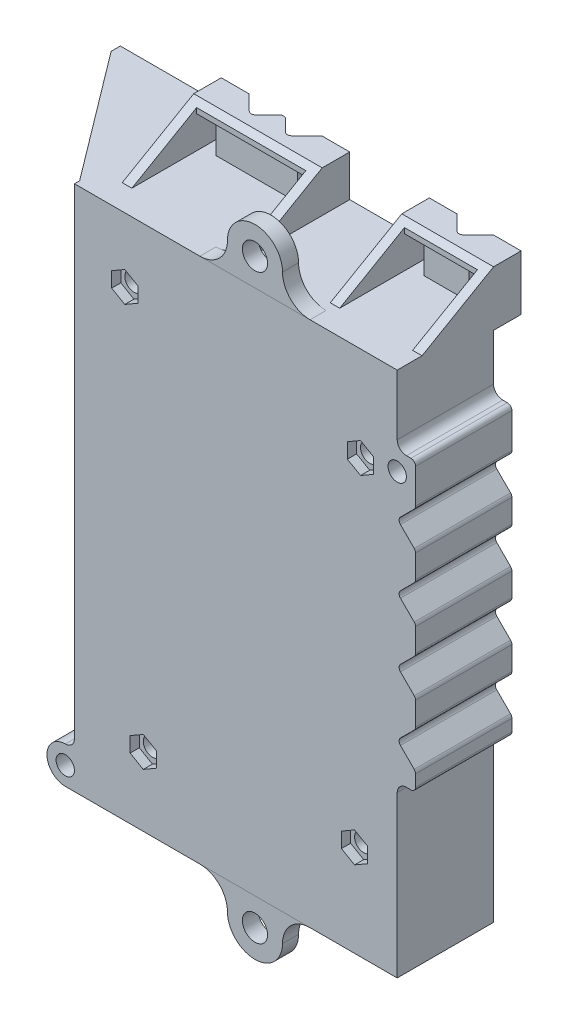
from build123d import *

# Parameters (mm, degrees)
BOSS_EXTRUDE1_DEPTH   = 21
FILLET1_R             = 2
SKETCH2_W             = 64.35
SKETCH2_H             = 108.75
CUT_EXTRUDE1_DEPTH    = 17.5
SKETCH3_R             = 2.75
BOSS_EXTRUDE2_DEPTH   = 3.5
BOSS_EXTRUDE2_2_DEPTH = 3.5
BOSS_EXTRUDE4_DEPTH   = 21
SKETCH6_R             = 2
CUT_EXTRUDE2_DEPTH    = 22
BOSS_EXTRUDE5_DEPTH   = 10
SKETCH8_R             = 2
CUT_EXTRUDE3_DEPTH    = 10
BOSS_EXTRUDE6_DEPTH   = 23
CUT_EXTRUDE5_DEPTH    = 17
SKETCH11_W            = 1.027963803
SKETCH11_H            = 17
CUT_EXTRUDE6_DEPTH    = 27.5
SKETCH12_W            = 67.35
SKETCH12_H            = 3
CUT_EXTRUDE7_DEPTH    = 4
SKETCH13_W            = 15
SKETCH13_H            = 13
CUT_EXTRUDE8_DEPTH    = 4
BOSS_EXTRUDE7_DEPTH   = 20
CUT_EXTRUDE9_DEPTH    = 20
CUT_EXTRUDE10_START   = -21.58846
SKETCH16_W            = 3.00025
SKETCH16_H            = 7.000001577
CUT_EXTRUDE10_DEPTH   = 21.58846
SKETCH17_W            = 15.9
SKETCH17_H            = 8.154711577
CUT_EXTRUDE11_DEPTH   = 19.5359
SKETCH18_W            = 9.8995
SKETCH18_H            = 7.000001577
CUT_EXTRUDE12_DEPTH   = 1.2
BOSS_EXTRUDE8_DEPTH   = 9
CUT_EXTRUDE13_DEPTH   = 9
BOSS_EXTRUDE9_DEPTH   = 28
CUT_EXTRUDE14_START   = -21.58846
SKETCH21_W            = 3
SKETCH21_H            = 7
CUT_EXTRUDE14_DEPTH   = 21.58846
SKETCH24_W            = 23.8
SKETCH24_H            = 8.15471
CUT_EXTRUDE15_DEPTH   = 16.0359
SKETCH25_W            = 17.8
SKETCH25_H            = 7
CUT_EXTRUDE16_DEPTH   = 1.2
BOSS_EXTRUDE10_DEPTH  = 3.5
SKETCH27_R            = 2
CUT_EXTRUDE20_DEPTH   = 4.5
CUT_EXTRUDE21_DEPTH   = 2
SKETCH34_R            = 4
SKETCH34_R_2          = 2
BOSS_EXTRUDE12_DEPTH  = 2
FILLET3_R             = 4
SKETCH35_R            = 2
CUT_EXTRUDE22_DEPTH   = 22
BOSS_EXTRUDE13_DEPTH  = 4
CUT_EXTRUDE23_START   = -7
SKETCH38_R            = 2
CUT_EXTRUDE23_DEPTH   = 4
CUT_EXTRUDE24_DEPTH   = 3


with BuildPart() as part:
    # Sketch1 → Boss-Extrude1 (new body)
    with BuildSketch(Plane.XY):
        with BuildLine():
            Line((38.175, 42.225), (35.175, 42.225))
            Line((35.175, 42.225), (35.175, 57.375))
            Line((35.175, 57.375), (-35.175, 57.375))
            Line((-35.175, 57.375), (-35.175, -57.375))
            Line((-35.175, -57.375), (35.175, -57.375))
            Line((35.175, -57.375), (35.175, -20.375))
            Line((35.175, -20.375), (38.175, -20.375))
            ThreePointArc((38.175, -20.375), (38.882106781, -20.082106781), (39.175, -19.375))
            Line((39.175, -19.375), (39.175, -16.839213562))
            ThreePointArc((39.175, -16.839213562), (39.098879533, -16.45653013), (38.882106781, -16.132106781))
            Line((38.882106781, -16.132106781), (35.882106781, -13.132106781))
            ThreePointArc((35.882106781, -13.132106781), (35.589213562, -12.425), (35.882106781, -11.717893219))
            Line((35.882106781, -11.717893219), (38.882106781, -8.717893219))
            ThreePointArc((38.882106781, -8.717893219), (39.098879533, -8.39346987), (39.175, -8.010786438))
            Line((39.175, -8.010786438), (39.175, -2.939213562))
            ThreePointArc((39.175, -2.939213562), (39.098879533, -2.55653013), (38.882106781, -2.232106781))
            Line((38.882106781, -2.232106781), (35.882106781, 0.767893219))
            ThreePointArc((35.882106781, 0.767893219), (35.589213562, 1.475), (35.882106781, 2.182106781))
            Line((35.882106781, 2.182106781), (38.882106781, 5.182106781))
            ThreePointArc((38.882106781, 5.182106781), (39.098879533, 5.50653013), (39.175, 5.889213562))
            Line((39.175, 5.889213562), (39.175, 10.960786438))
            ThreePointArc((39.175, 10.960786438), (39.098879533, 11.34346987), (38.882106781, 11.667893219))
            Line((38.882106781, 11.667893219), (35.882106781, 14.667893219))
            ThreePointArc((35.882106781, 14.667893219), (35.589213562, 15.375), (35.882106781, 16.082106781))
            Line((35.882106781, 16.082106781), (38.882106781, 19.082106781))
            ThreePointArc((38.882106781, 19.082106781), (39.098879533, 19.40653013), (39.175, 19.789213562))
            Line((39.175, 19.789213562), (39.175, 24.860786438))
            ThreePointArc((39.175, 24.860786438), (39.098879533, 25.24346987), (38.882106781, 25.567893219))
            Line((38.882106781, 25.567893219), (35.882106781, 28.567893219))
            ThreePointArc((35.882106781, 28.567893219), (35.589213562, 29.275), (35.882106781, 29.982106781))
            Line((35.882106781, 29.982106781), (38.882106781, 32.982106781))
            ThreePointArc((38.882106781, 32.982106781), (39.098879533, 33.30653013), (39.175, 33.689213562))
            Line((39.175, 33.689213562), (39.175, 41.225))
            ThreePointArc((39.175, 41.225), (38.882106781, 41.932106781), (38.175, 42.225))
        make_face()
    extrude(amount=BOSS_EXTRUDE1_DEPTH)

    # Fillet1
    fillet1_edges = [part.edges().sort_by_distance(p)[0] for p in [
        (35.175, 42.225, 10.5),
        (35.175, -20.375, 10.5),
    ]]
    fillet(fillet1_edges, radius=FILLET1_R)

    # Sketch2 → Cut-Extrude1 (cut)
    with BuildSketch(Plane(origin=(0, 0, 0), x_dir=(-1, 0, 0), z_dir=(0, 0, -1))):
        Rectangle(SKETCH2_W, SKETCH2_H)
    extrude(amount=-CUT_EXTRUDE1_DEPTH, mode=Mode.SUBTRACT)

    # Sketch5 → Boss-Extrude4 (add)
    with BuildSketch(Plane.XY.offset(21)):
        with BuildLine():
            Line((-35.175, -47.375), (-35.175, -57.375))
            Line((-35.175, -57.375), (-37.175, -57.375))
            ThreePointArc((-37.175, -57.375), (-41.175, -53.375), (-37.175, -49.375))
            ThreePointArc((-37.175, -49.375), (-35.760786438, -48.789213562), (-35.175, -47.375))
        make_face()
    extrude(amount=-BOSS_EXTRUDE4_DEPTH)

    # Sketch6 → Cut-Extrude2 (cut, through all)
    with BuildSketch(Plane.XY.offset(21)):
        with Locations((-37.175, -53.375)):
            Circle(SKETCH6_R)
    extrude(amount=-CUT_EXTRUDE2_DEPTH, mode=Mode.SUBTRACT)

    # Sketch7 → Boss-Extrude5 (add)
    with BuildSketch(Plane(origin=(0, 0, 0), x_dir=(-1, 0, 0), z_dir=(0, 0, -1))):
        Polygon((-35.175, 57.375), (-35.175, 54.375), (32.175, 54.375), (32.175, 22.375), (35.175, 22.375), (35.175, 57.375), align=None)
    extrude(amount=BOSS_EXTRUDE5_DEPTH)

    # Sketch8 → Cut-Extrude3 (cut)
    with BuildSketch(Plane.ZY.offset(35.175)):
        with Locations((8.68916164, -13.263185313)):
            Circle(SKETCH8_R)
        with Locations((8.68916164, 22.513185313)):
            Circle(SKETCH8_R)
        with BuildLine():
            Line((0, -13.841185313), (0, 22.375))
            Line((0, 22.375), (-10, 22.375))
            Line((-10, 22.375), (-10, 25.625))
            ThreePointArc((-10, 25.625), (10.356692899, 9.783008745), (0, -13.841185313))
        make_face()
    extrude(amount=-CUT_EXTRUDE3_DEPTH, mode=Mode.SUBTRACT)

    # Sketch9 → Boss-Extrude6 (add)
    with BuildSketch(Plane(origin=(0, 57.375, 0), x_dir=(1, 0, 0), z_dir=(0, 1, 0))):
        Polygon((-35.175, -19.86794), (-56.174999055, 8), (-56.174999055, 10), (-35.175, 10), align=None)
    extrude(amount=-BOSS_EXTRUDE6_DEPTH)

    # Sketch10 → Cut-Extrude5 (cut)
    with BuildSketch(Plane(origin=(0, 54.375, 0), x_dir=(1, 0, 0), z_dir=(0, 1, 0))):
        Polygon((-33.202963803, 10), (-33.202963803, -17.5), (-53.925700181, 10), align=None)
    extrude(amount=-CUT_EXTRUDE5_DEPTH, mode=Mode.SUBTRACT)

    # Sketch11 → Cut-Extrude6 (cut)
    with BuildSketch(Plane(origin=(0, 0, -10), x_dir=(-1, 0, 0), z_dir=(0, 0, -1))):
        with Locations((32.688981902, 45.875)):
            Rectangle(SKETCH11_W, SKETCH11_H)
    extrude(amount=-CUT_EXTRUDE6_DEPTH, mode=Mode.SUBTRACT)

    # Sketch12 → Cut-Extrude7 (cut)
    with BuildSketch(Plane(origin=(0, 0, -10), x_dir=(-1, 0, 0), z_dir=(0, 0, -1))):
        with Locations((-1.5, 55.875)):
            Rectangle(SKETCH12_W, SKETCH12_H)
    extrude(amount=-CUT_EXTRUDE7_DEPTH, mode=Mode.SUBTRACT)

    # Sketch13 → Cut-Extrude8 (cut)
    with BuildSketch(Plane.XZ.offset(57.375)):
        with Locations((14.975, 6.5)):
            Rectangle(SKETCH13_W, SKETCH13_H)
    extrude(amount=-CUT_EXTRUDE8_DEPTH, mode=Mode.SUBTRACT)

    # Sketch14 → Boss-Extrude7 (add)
    with BuildSketch(Plane(origin=(35.175, 0, 0), x_dir=(0, 0, -1), z_dir=(1, 0, 0))):
        Polygon((-15.58846, 57.375), (0, 66.375001577), (6, 66.375001577), (6, 57.375), align=None)
    extrude(amount=-BOSS_EXTRUDE7_DEPTH)

    # Sketch15 → Cut-Extrude9 (cut)
    with BuildSketch(Plane(origin=(0, 66.375001577, 0), x_dir=(1, 0, 0), z_dir=(0, 1, 0))):
        with BuildLine():
            Line((25.882106079, 2.757362517), (29.12475, 6))
            Line((29.12475, 6), (21.22525, 6))
            Line((21.22525, 6), (24.467893921, 2.757362517))
            ThreePointArc((24.467893921, 2.757362517), (25.175, 2.46447), (25.882106079, 2.757362517))
        make_face()
    extrude(amount=-CUT_EXTRUDE9_DEPTH, mode=Mode.SUBTRACT)

    # Sketch16 → Cut-Extrude10 (cut)
    with BuildSketch(Plane(origin=(0, 0, -6), x_dir=(-1, 0, 0), z_dir=(0, 0, -1)).offset(CUT_EXTRUDE10_START)):
        with Locations((-18.725125, 60.875000789)):
            Rectangle(SKETCH16_W, SKETCH16_H)
        with Locations((-31.624875, 60.875000789)):
            Rectangle(SKETCH16_W, SKETCH16_H)
    extrude(amount=CUT_EXTRUDE10_DEPTH, mode=Mode.SUBTRACT)

    # Sketch17 → Cut-Extrude11 (cut)
    with BuildSketch(Plane.XY.offset(21)):
        with Locations((25.175, 61.452355789)):
            Rectangle(SKETCH17_W, SKETCH17_H)
    extrude(amount=-CUT_EXTRUDE11_DEPTH, mode=Mode.SUBTRACT)

    # Sketch18 → Cut-Extrude12 (cut)
    with BuildSketch(Plane.XY.offset(1.4641)):
        with Locations((25.175, 60.875000789)):
            Rectangle(SKETCH18_W, SKETCH18_H)
    extrude(amount=-CUT_EXTRUDE12_DEPTH, mode=Mode.SUBTRACT)

    # Sketch19 → Boss-Extrude8 (add)
    with BuildSketch(Plane(origin=(0, 57.375, 0), x_dir=(1, 0, 0), z_dir=(0, 1, 0))):
        with BuildLine():
            Line((-30.175, 6), (-24.075, 6))
            Line((-24.075, 6), (-20.832106781, 2.757106781))
            ThreePointArc((-20.832106781, 2.757106781), (-20.125, 2.464213562), (-19.417893219, 2.757106781))
            Line((-19.417893219, 2.757106781), (-16.882106781, 5.292893219))
            ThreePointArc((-16.882106781, 5.292893219), (-16.175, 5.585786438), (-15.467893219, 5.292893219))
            Line((-15.467893219, 5.292893219), (-12.932106781, 2.757106781))
            ThreePointArc((-12.932106781, 2.757106781), (-12.225, 2.464213562), (-11.517893219, 2.757106781))
            Line((-11.517893219, 2.757106781), (-8.275, 6))
            Line((-8.275, 6), (-2.175, 6))
            Line((-2.175, 6), (-2.175, 0))
            Line((-2.175, 0), (-30.175, 0))
            Line((-30.175, 0), (-30.175, 6))
        make_face()
    extrude(amount=BOSS_EXTRUDE8_DEPTH)

    # Sketch20 → Cut-Extrude13 (cut)
    with BuildSketch(Plane(origin=(0, 57.375, 0), x_dir=(1, 0, 0), z_dir=(0, 1, 0))):
        with BuildLine():
            Line((-24.075, 6), (-8.275, 6))
            Line((-8.275, 6), (-11.517893219, 2.757106781))
            ThreePointArc((-11.517893219, 2.757106781), (-12.225, 2.464213562), (-12.932106781, 2.757106781))
            Line((-12.932106781, 2.757106781), (-15.467893219, 5.292893219))
            ThreePointArc((-15.467893219, 5.292893219), (-16.175, 5.585786438), (-16.882106781, 5.292893219))
            Line((-16.882106781, 5.292893219), (-19.417893219, 2.757106781))
            ThreePointArc((-19.417893219, 2.757106781), (-20.125, 2.464213562), (-20.832106781, 2.757106781))
            Line((-20.832106781, 2.757106781), (-24.075, 6))
        make_face()
    extrude(amount=-CUT_EXTRUDE13_DEPTH, mode=Mode.SUBTRACT)

    # Sketch23 → Boss-Extrude9 (add)
    with BuildSketch(Plane.ZY.offset(30.175)):
        Polygon((0, 66.375), (15.58846, 57.375), (0, 57.375), align=None)
    extrude(amount=-BOSS_EXTRUDE9_DEPTH)

    # Sketch21 → Cut-Extrude14 (cut)
    with BuildSketch(Plane(origin=(0, 0, -6), x_dir=(-1, 0, 0), z_dir=(0, 0, -1)).offset(CUT_EXTRUDE14_START)):
        with Locations((26.575, 60.875)):
            Rectangle(SKETCH21_W, SKETCH21_H)
        with Locations((5.775, 60.875)):
            Rectangle(SKETCH21_W, SKETCH21_H)
    extrude(amount=CUT_EXTRUDE14_DEPTH, mode=Mode.SUBTRACT)

    # Sketch24 → Cut-Extrude15 (cut)
    with BuildSketch(Plane.XY.offset(17.5)):
        with Locations((-16.175, 61.452355)):
            Rectangle(SKETCH24_W, SKETCH24_H)
    extrude(amount=-CUT_EXTRUDE15_DEPTH, mode=Mode.SUBTRACT)

    # Sketch25 → Cut-Extrude16 (cut)
    with BuildSketch(Plane.XY.offset(1.4641)):
        with Locations((-16.175, 60.875)):
            Rectangle(SKETCH25_W, SKETCH25_H)
    extrude(amount=-CUT_EXTRUDE16_DEPTH, mode=Mode.SUBTRACT)

    # Sketch26 → Boss-Extrude10 (add)
    with BuildSketch(Plane(origin=(0, 0, 17.5), x_dir=(-1, 0, 0), z_dir=(0, 0, -1))):
        with BuildLine():
            Line((-19.175, 31.875), (-19.175, -26.875))
            ThreePointArc((-19.175, -26.875), (-21.675, -29.375), (-24.175, -26.875))
            Line((-24.175, -26.875), (-24.175, 31.875))
            ThreePointArc((-24.175, 31.875), (-21.675, 34.375), (-19.175, 31.875))
        make_face()
        with BuildLine():
            Line((17.04135, 31.875), (17.04135, -26.875))
            ThreePointArc((17.04135, -26.875), (14.54135, -29.375), (12.04135, -26.875))
            Line((12.04135, -26.875), (12.04135, 31.875))
            ThreePointArc((12.04135, 31.875), (14.54135, 34.375), (17.04135, 31.875))
        make_face()
    extrude(amount=BOSS_EXTRUDE10_DEPTH)

    # Sketch27 → Cut-Extrude20 (cut, through all)
    with BuildSketch(Plane(origin=(0, 0, 17.5), x_dir=(-1, 0, 0), z_dir=(0, 0, -1))):
        with Locations((20.175, -42.375)):
            Circle(SKETCH27_R)
        with Locations((-25.875, -37.375)):
            Circle(SKETCH27_R)
        with Locations((24.202963803, 43.375)):
            Circle(SKETCH27_R)
        with Locations((-27.175, 36.775)):
            Circle(SKETCH27_R)
    extrude(amount=-CUT_EXTRUDE20_DEPTH, mode=Mode.SUBTRACT)

    # Sketch32 → Cut-Extrude21 (cut)
    with BuildSketch(Plane.XY.offset(21)):
        Polygon((-21.34507997, 41.725), (-21.34507997, 45.025), (-24.202963803, 46.675), (-27.060847635, 45.025), (-27.060847635, 41.725), (-24.202963803, 40.075), align=None)
        Polygon((30.032883832, 35.125), (30.032883832, 38.425), (27.175, 40.075), (24.317116168, 38.425), (24.317116168, 35.125), (27.175, 33.475), align=None)
        Polygon((-17.317116168, -44.025), (-17.317116168, -40.725), (-20.175, -39.075), (-23.032883832, -40.725), (-23.032883832, -44.025), (-20.175, -45.675), align=None)
        Polygon((28.732883832, -39.025), (28.732883832, -35.725), (25.875, -34.075), (23.017116168, -35.725), (23.017116168, -39.025), (25.875, -40.675), align=None)
    extrude(amount=-CUT_EXTRUDE21_DEPTH, mode=Mode.SUBTRACT)

    # Sketch34 → Boss-Extrude12 (add)
    with BuildSketch(Plane(origin=(0, 0, 17.5), x_dir=(-1, 0, 0), z_dir=(0, 0, -1))):
        with Locations((-27.175, 36.775)):
            Circle(SKETCH34_R)
        with Locations((-27.175, 36.775)):
            Circle(SKETCH34_R_2, mode=Mode.SUBTRACT)
        with BuildLine():
            ThreePointArc((-27.175, 32.775), (-31.175, 36.775), (-27.175, 40.775))
            Line((-27.175, 40.775), (-32.175, 40.775))
            Line((-32.175, 40.775), (-32.175, 32.775))
            Line((-32.175, 32.775), (-27.175, 32.775))
        make_face()
        with Locations((24.112183156, 43.39205956)):
            Circle(SKETCH34_R)
        with Locations((24.202963803, 43.375)):
            Circle(SKETCH34_R_2, mode=Mode.SUBTRACT)
        with Locations((20.175, -42.375)):
            Circle(SKETCH34_R)
        with Locations((20.175, -42.375)):
            Circle(SKETCH34_R_2, mode=Mode.SUBTRACT)
        with BuildLine():
            Line((-25.875, -33.375), (-32.175, -33.375))
            Line((-32.175, -33.375), (-32.175, -41.375))
            Line((-32.175, -41.375), (-25.875, -41.375))
            ThreePointArc((-25.875, -41.375), (-29.875, -37.375), (-25.875, -33.375))
        make_face()
        with Locations((-25.875, -37.375)):
            Circle(SKETCH34_R)
        with Locations((-25.875, -37.375)):
            Circle(SKETCH34_R_2, mode=Mode.SUBTRACT)
    extrude(amount=BOSS_EXTRUDE12_DEPTH)

    # Fillet3
    fillet3_edges = [part.edges().sort_by_distance(p)[0] for p in [
        (32.175, 40.775, 16.5),
        (32.175, 32.775, 16.5),
        (32.175, -41.375, 16.5),
        (32.175, -33.375, 16.5),
    ]]
    fillet(fillet3_edges, radius=FILLET3_R)

    # Sketch35 → Cut-Extrude22 (cut, through all)
    with BuildSketch(Plane(origin=(0, 0, 0), x_dir=(-1, 0, 0), z_dir=(0, 0, -1))):
        with Locations((-35.175, 38.225)):
            Circle(SKETCH35_R)
    extrude(amount=-CUT_EXTRUDE22_DEPTH, mode=Mode.SUBTRACT)

    # Sketch36 → Boss-Extrude13 (add)
    with BuildSketch(Plane(origin=(-32.175, 0, 0), x_dir=(0, 0, -1), z_dir=(1, 0, 0))):
        with BuildLine():
            Line((-17.5, 27.496380363), (-17.5, 15.496380363))
            Line((-17.5, 15.496380363), (-7.967, 15.496380363))
            ThreePointArc((-7.967, 15.496380363), (-6.376511507, 17.770716825), (-4.5, 19.815457531))
            Line((-4.5, 19.815457531), (-4.5, 27.496380363))
            Line((-4.5, 27.496380363), (-17.5, 27.496380363))
        make_face()
    boss_extrude13 = extrude(amount=BOSS_EXTRUDE13_DEPTH)

    # Mirror1: Boss-Extrude13 across plane
    add(boss_extrude13.mirror(Plane(origin=(0, 4.625, 0), x_dir=(0, 0, 1), z_dir=(0, -1, 0))))

    # Sketch38 → Cut-Extrude23 (cut)
    with BuildSketch(Plane.ZY.offset(35.175).offset(CUT_EXTRUDE23_START)):
        with Locations((8.68916164, -13.263185313)):
            Circle(SKETCH38_R)
        with Locations((8.68916164, 22.513185313)):
            Circle(SKETCH38_R)
    extrude(amount=CUT_EXTRUDE23_DEPTH, mode=Mode.SUBTRACT)

    # Sketch39 → Cut-Extrude24 (cut)
    with BuildSketch(Plane(origin=(-28.175, 0, 0), x_dir=(0, 0, -1), z_dir=(1, 0, 0))):
        Polygon((-5.839158639, 24.158635313), (-8.68916164, 25.804085313), (-11.539164641, 24.158635313), (-11.539164641, 20.867735313), (-8.68916164, 19.222285313), (-5.839158639, 20.867735313), align=None)
    cut_extrude24 = extrude(amount=-CUT_EXTRUDE24_DEPTH, mode=Mode.SUBTRACT)

    # Mirror2: Cut-Extrude24 across plane
    add(cut_extrude24.mirror(Plane(origin=(0, 4.625, 0), x_dir=(0, 0, 1), z_dir=(0, -1, 0))), mode=Mode.SUBTRACT)


with BuildPart() as body_2:
    # Sketch3 → Boss-Extrude2 (new body)
    with BuildSketch(Plane.XY.offset(21)):
        with BuildLine():
            Line((-7.825, 57.375), (16.175, 57.375))
            ThreePointArc((16.175, 57.375), (11.932359313, 59.132359313), (10.175, 63.375))
            ThreePointArc((10.175, 63.375), (4.175, 69.375), (-1.825, 63.375))
            ThreePointArc((-1.825, 63.375), (-3.582359313, 59.132359313), (-7.825, 57.375))
        make_face()
        with Locations((4.175, 63.375)):
            Circle(SKETCH3_R, mode=Mode.SUBTRACT)
    extrude(amount=-BOSS_EXTRUDE2_DEPTH)


with BuildPart() as body_3:
    # Sketch3 → Boss-Extrude2 2 (new body)
    with BuildSketch(Plane.XY.offset(21)):
        with BuildLine():
            Line((-7.825, -57.375), (16.175, -57.375))
            ThreePointArc((16.175, -57.375), (11.932359313, -59.132359313), (10.175, -63.375))
            ThreePointArc((10.175, -63.375), (4.175, -69.375), (-1.825, -63.375))
            ThreePointArc((-1.825, -63.375), (-3.582359313, -59.132359313), (-7.825, -57.375))
        make_face()
        with Locations((4.175, -63.375)):
            Circle(SKETCH3_R, mode=Mode.SUBTRACT)
    extrude(amount=-BOSS_EXTRUDE2_2_DEPTH)


solid = Compound([part.part, body_2.part, body_3.part])
